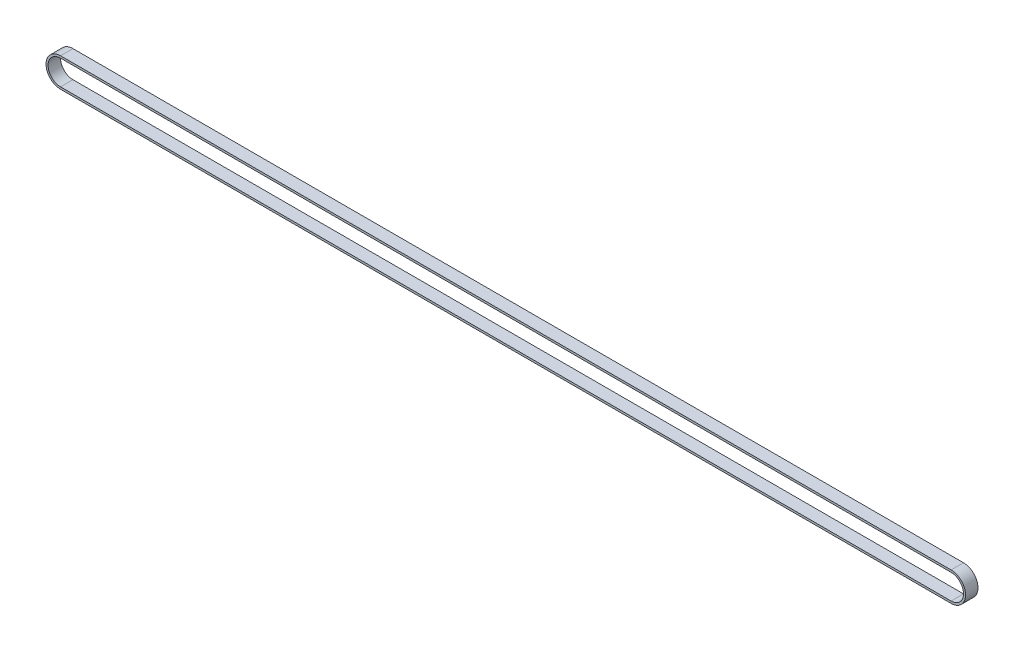
from build123d import *

# Parameters (mm, degrees)
BOSS_EXTRUDE1_DEPTH = 6


with BuildPart() as part:
    # Sketch1 → Boss-Extrude1 (new body)
    with BuildSketch(Plane.XY):
        with BuildLine():
            Line((0, 7), (430, 7))
            ThreePointArc((430, 7), (437, 0), (430, -7))
            Line((430, -7), (0, -7))
            ThreePointArc((0, -7), (-7, 0), (0, 7))
        make_face()
        with BuildLine():
            Line((0, 6), (430, 6))
            ThreePointArc((430, 6), (436, 0), (430, -6))
            Line((430, -6), (0, -6))
            ThreePointArc((0, -6), (-6, 0), (0, 6))
        make_face(mode=Mode.SUBTRACT)
    extrude(amount=BOSS_EXTRUDE1_DEPTH)


solid = part.part
